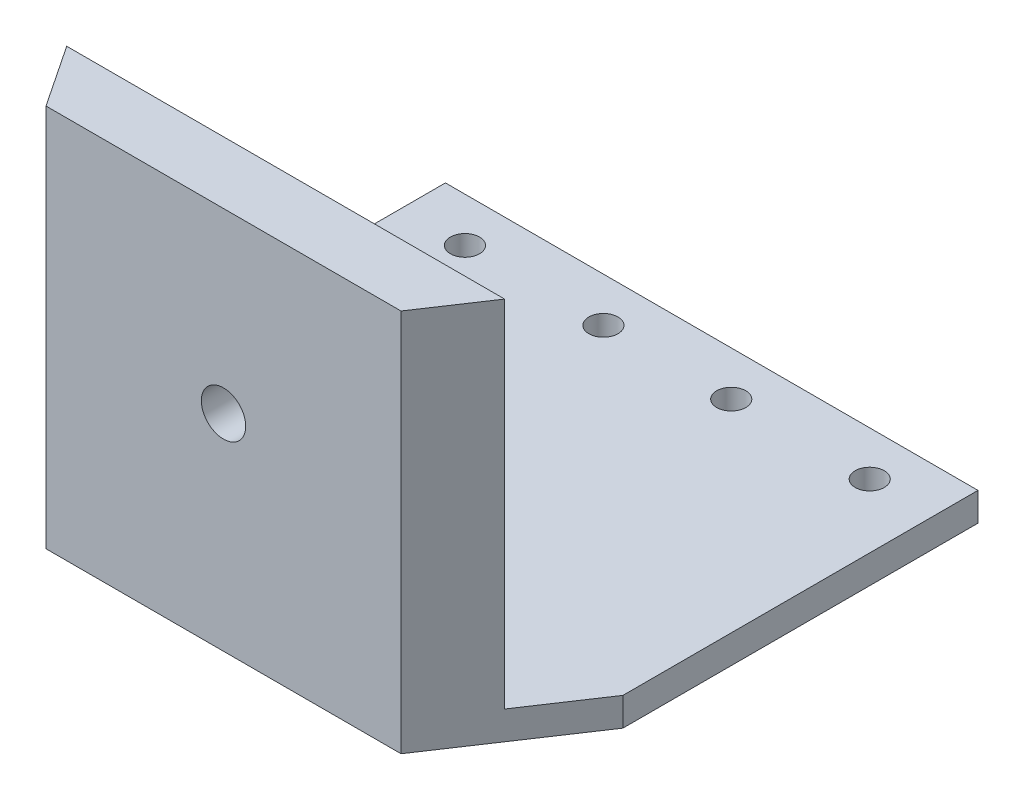
from build123d import *

# Parameters (mm, degrees)
SKETCH1_W           = 76.2
SKETCH1_H           = 50.8
SKETCH1_R           = 2.0828
BOSS_EXTRUDE1_DEPTH = 2.032
BOSS_EXTRUDE2_DEPTH = 50.8
CUT_EXTRUDE1_DEPTH  = 9.89


with BuildPart() as part:
    # Sketch1 → Boss-Extrude1 (new body, symmetric)
    with BuildSketch(Plane(origin=(0, 0, 0), x_dir=(1, 0, 0), z_dir=(0, 1, 0))):
        Rectangle(SKETCH1_W, SKETCH1_H)
        with Locations((28.956, 19.05)):
            Circle(SKETCH1_R, mode=Mode.SUBTRACT)
        with Locations((9.144, 19.05)):
            Circle(SKETCH1_R, mode=Mode.SUBTRACT)
        with Locations((-9.144, 19.05)):
            Circle(SKETCH1_R, mode=Mode.SUBTRACT)
        with Locations((-28.956, 19.05)):
            Circle(SKETCH1_R, mode=Mode.SUBTRACT)
        Polygon((-25.4, -44.45), (25.4, -44.45), (38.1, -25.4), (-38.1, -25.4), align=None)
    extrude(amount=BOSS_EXTRUDE1_DEPTH, both=True)

    # Sketch2 → Boss-Extrude2 (add)
    with BuildSketch(Plane(origin=(0, 2.032, 0), x_dir=(1, 0, 0), z_dir=(0, 1, 0))):
        Polygon((-31.326666667, -35.56), (-25.4, -44.45), (25.4, -44.45), (31.326666667, -35.56), align=None)
    extrude(amount=BOSS_EXTRUDE2_DEPTH)

    # Sketch3 → Cut-Extrude1 (cut, through all)
    with BuildSketch(Plane(origin=(0, 0, 35.56), x_dir=(-1, 0, 0), z_dir=(0, 0, -1))):
        with BuildLine():
            ThreePointArc((-2.466199502, 25.432378782), (0, 24.257), (2.466199502, 25.432378782))
            Line((2.466199502, 25.432378782), (0, 27.432))
            Line((0, 27.432), (-2.466199502, 25.432378782))
        make_face()
        with BuildLine():
            Line((0, 27.432), (2.466199502, 25.432378782))
            ThreePointArc((2.466199502, 25.432378782), (2.992558138, 26.371235752), (3.175, 27.432))
            ThreePointArc((3.175, 27.432), (2.992558138, 28.492764248), (2.466199502, 29.431621218))
            Line((2.466199502, 29.431621218), (0, 27.432))
        make_face()
        with BuildLine():
            Line((-2.466199502, 25.432378782), (0, 27.432))
            Line((0, 27.432), (-2.466199502, 29.431621218))
            ThreePointArc((-2.466199502, 29.431621218), (-3.175, 27.432), (-2.466199502, 25.432378782))
        make_face()
        with BuildLine():
            Line((-2.466199502, 29.431621218), (0, 27.432))
            Line((0, 27.432), (2.466199502, 29.431621218))
            ThreePointArc((2.466199502, 29.431621218), (0, 30.607), (-2.466199502, 29.431621218))
        make_face()
    extrude(amount=-CUT_EXTRUDE1_DEPTH, mode=Mode.SUBTRACT)


solid = part.part
